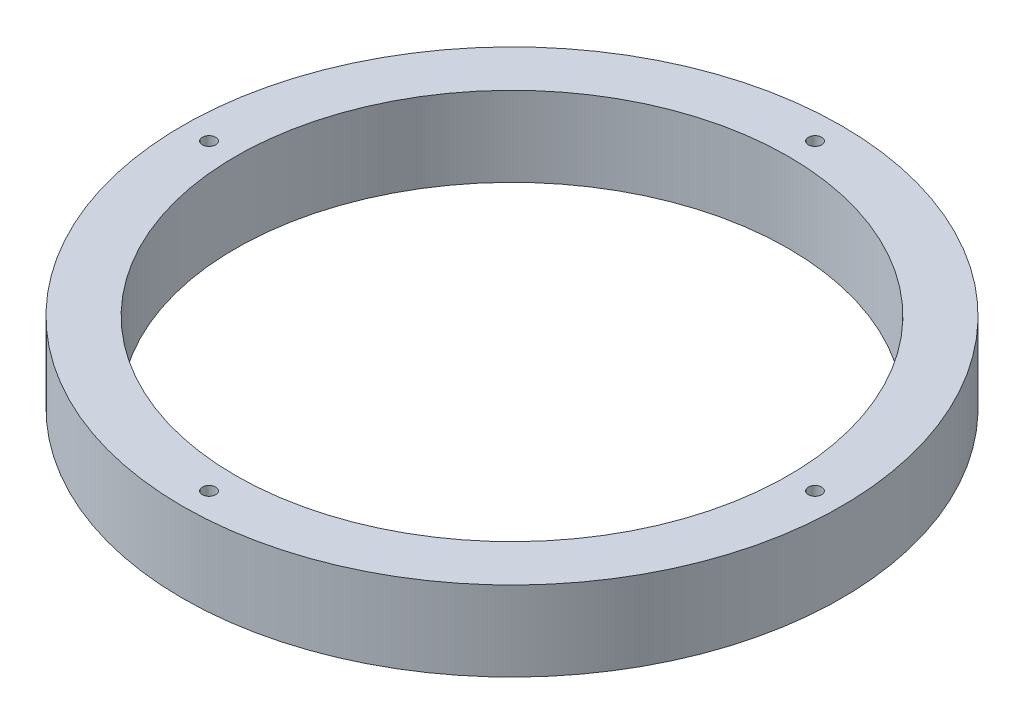
from build123d import *

# Parameters (mm, degrees)
SKETCH1_R           = 39.37
SKETCH1_R_2         = 33.02
SKETCH1_R_3         = 0.79375
BOSS_EXTRUDE1_DEPTH = 9.525


with BuildPart() as part:
    # Sketch1 → Boss-Extrude1 (new body)
    with BuildSketch(Plane(origin=(0, 0, 0), x_dir=(1, 0, 0), z_dir=(0, 1, 0))):
        Circle(SKETCH1_R)
        Circle(SKETCH1_R_2, mode=Mode.SUBTRACT)
        with Locations((0, 36.195)):
            Circle(SKETCH1_R_3, mode=Mode.SUBTRACT)
        with Locations((36.195, 0)):
            Circle(SKETCH1_R_3, mode=Mode.SUBTRACT)
        with Locations((0, -36.195)):
            Circle(SKETCH1_R_3, mode=Mode.SUBTRACT)
        with Locations((-36.195, 0)):
            Circle(SKETCH1_R_3, mode=Mode.SUBTRACT)
    extrude(amount=BOSS_EXTRUDE1_DEPTH)


solid = part.part
